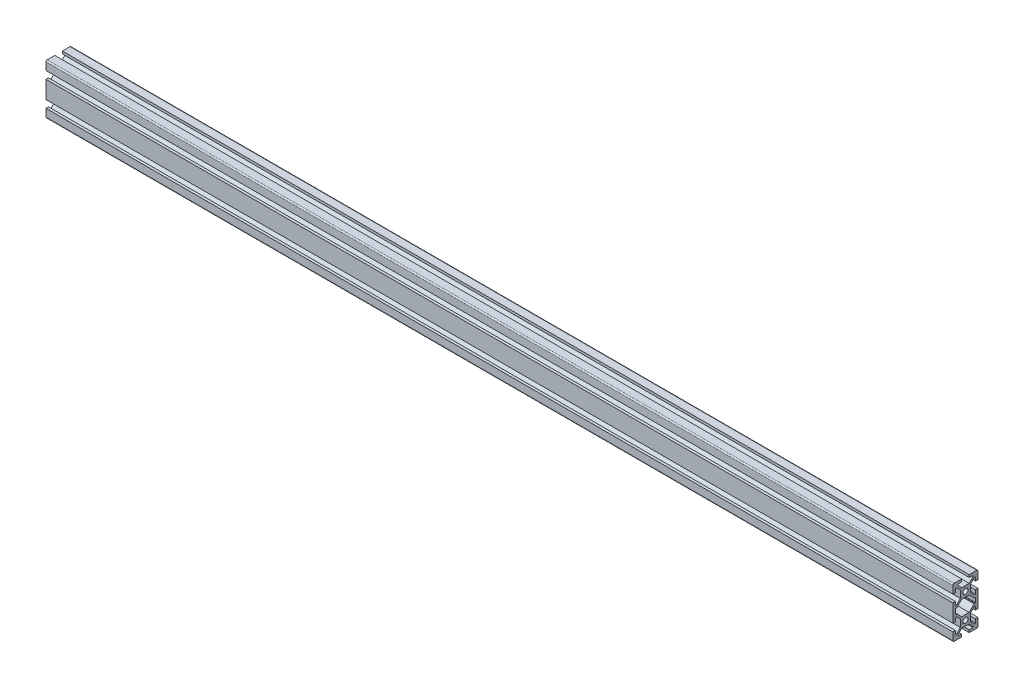
from build123d import *

# Parameters (mm, degrees)
SKETCH1_R           = 2.1
BOSS_EXTRUDE1_DEPTH = 722


with BuildPart() as part:
    # Sketch1 → Boss-Extrude1 (new body)
    with BuildSketch(Plane(origin=(0, 0, 0), x_dir=(0, 0, -1), z_dir=(1, 0, 0))):
        with BuildLine():
            Line((-10, -13), (-10, -19))
            ThreePointArc((-10, -19), (-9.707106781, -19.707106781), (-9, -20))
            Line((-9, -20), (-3, -20))
            Line((-3, -20), (-3, -18))
            Line((-3, -18), (-6, -18))
            Line((-6, -18), (-6, -17.060660172))
            Line((-6, -17.060660172), (-2.939339828, -14))
            Line((-2.939339828, -14), (2.939339828, -14))
            Line((2.939339828, -14), (6, -17.060660172))
            Line((6, -17.060660172), (6, -18))
            Line((6, -18), (3, -18))
            Line((3, -18), (3, -20))
            Line((3, -20), (9, -20))
            ThreePointArc((9, -20), (9.707106781, -19.707106781), (10, -19))
            Line((10, -19), (10, -13))
            Line((10, -13), (8, -13))
            Line((8, -13), (8, -16))
            Line((8, -16), (7.060660172, -16))
            Line((7.060660172, -16), (4, -12.939339828))
            Line((4, -12.939339828), (4, -7.060660172))
            Line((4, -7.060660172), (7.060660172, -4))
            Line((7.060660172, -4), (8, -4))
            Line((8, -4), (8, -7))
            Line((8, -7), (10, -7))
            Line((10, -7), (10, 7))
            Line((10, 7), (8, 7))
            Line((8, 7), (8, 4))
            Line((8, 4), (7.060660172, 4))
            Line((7.060660172, 4), (4, 7.060660172))
            Line((4, 7.060660172), (4, 12.939339828))
            Line((4, 12.939339828), (7.060660172, 16))
            Line((7.060660172, 16), (8, 16))
            Line((8, 16), (8, 13))
            Line((8, 13), (10, 13))
            Line((10, 13), (10, 19))
            ThreePointArc((10, 19), (9.707106781, 19.707106781), (9, 20))
            Line((9, 20), (3, 20))
            Line((3, 20), (3, 18))
            Line((3, 18), (6, 18))
            Line((6, 18), (6, 17.060660172))
            Line((6, 17.060660172), (2.939339828, 14))
            Line((2.939339828, 14), (-2.939339828, 14))
            Line((-2.939339828, 14), (-6, 17.060660172))
            Line((-6, 17.060660172), (-6, 18))
            Line((-6, 18), (-3, 18))
            Line((-3, 18), (-3, 20))
            Line((-3, 20), (-9, 20))
            ThreePointArc((-9, 20), (-9.707106781, 19.707106781), (-10, 19))
            Line((-10, 19), (-10, 13))
            Line((-10, 13), (-8, 13))
            Line((-8, 13), (-8, 16))
            Line((-8, 16), (-7.060660172, 16))
            Line((-7.060660172, 16), (-4, 12.939339828))
            Line((-4, 12.939339828), (-4, 7.060660172))
            Line((-4, 7.060660172), (-7.060660172, 4))
            Line((-7.060660172, 4), (-8, 4))
            Line((-8, 4), (-8, 7))
            Line((-8, 7), (-10, 7))
            Line((-10, 7), (-10, -7))
            Line((-10, -7), (-8, -7))
            Line((-8, -7), (-8, -4))
            Line((-8, -4), (-7.060660172, -4))
            Line((-7.060660172, -4), (-4, -7.060660172))
            Line((-4, -7.060660172), (-4, -12.939339828))
            Line((-4, -12.939339828), (-7.060660172, -16))
            Line((-7.060660172, -16), (-8, -16))
            Line((-8, -16), (-8, -13))
            Line((-8, -13), (-10, -13))
        make_face()
        with Locations((0, 10)):
            Circle(SKETCH1_R, mode=Mode.SUBTRACT)
        with Locations((0, -10)):
            Circle(SKETCH1_R, mode=Mode.SUBTRACT)
        with BuildLine():
            Line((-8, 1.7), (-8, -1.7))
            ThreePointArc((-8, -1.7), (-7.912132034, -1.912132034), (-7.7, -2))
            Line((-7.7, -2), (-7.063603897, -2))
            ThreePointArc((-7.063603897, -2), (-6.948798867, -2.02283614), (-6.851471863, -2.087867966))
            Line((-6.851471863, -2.087867966), (-2.939339828, -6))
            Line((-2.939339828, -6), (2.939339828, -6))
            Line((2.939339828, -6), (6.851471863, -2.087867966))
            ThreePointArc((6.851471863, -2.087867966), (6.948798867, -2.02283614), (7.063603897, -2))
            Line((7.063603897, -2), (7.7, -2))
            ThreePointArc((7.7, -2), (7.912132034, -1.912132034), (8, -1.7))
            Line((8, -1.7), (8, 1.7))
            ThreePointArc((8, 1.7), (7.912132034, 1.912132034), (7.7, 2))
            Line((7.7, 2), (7.063603897, 2))
            ThreePointArc((7.063603897, 2), (6.948798867, 2.02283614), (6.851471863, 2.087867966))
            Line((6.851471863, 2.087867966), (2.939339828, 6))
            Line((2.939339828, 6), (-2.939339828, 6))
            Line((-2.939339828, 6), (-6.851471863, 2.087867966))
            ThreePointArc((-6.851471863, 2.087867966), (-6.948798867, 2.02283614), (-7.063603897, 2))
            Line((-7.063603897, 2), (-7.7, 2))
            ThreePointArc((-7.7, 2), (-7.912132034, 1.912132034), (-8, 1.7))
        make_face(mode=Mode.SUBTRACT)
    extrude(amount=BOSS_EXTRUDE1_DEPTH)


solid = part.part
